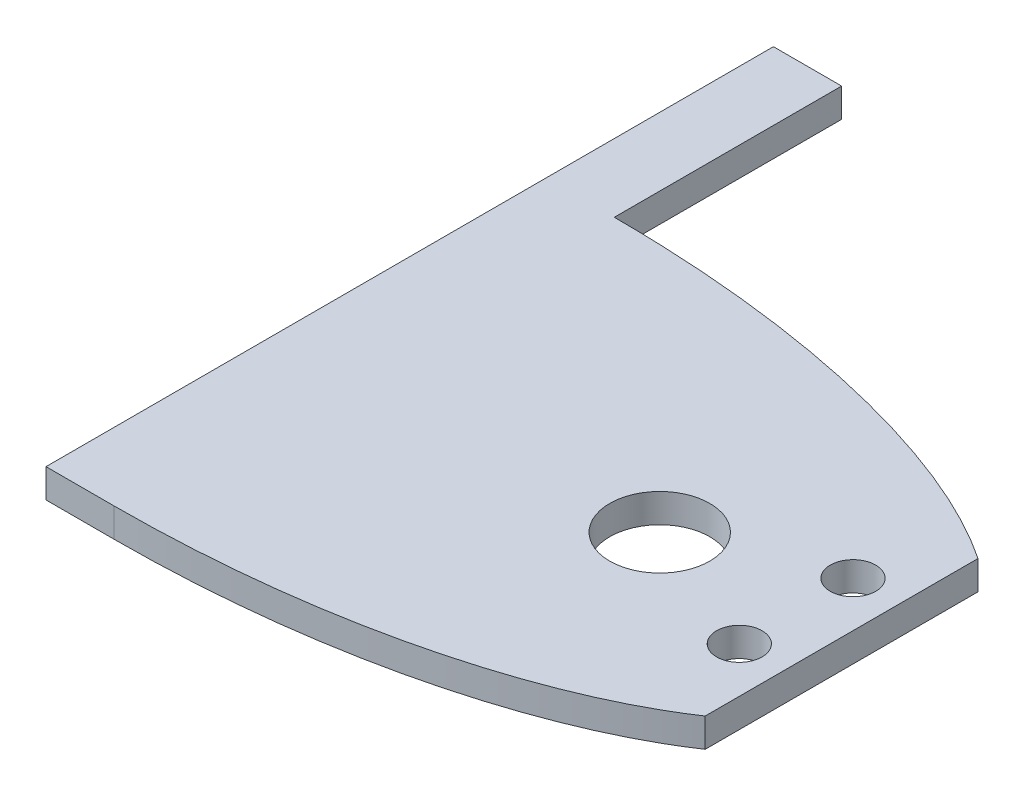
from build123d import *

# Parameters (mm, degrees)
BOSS_EXTRUDE1_DEPTH = 6.35
SKETCH2_R           = 5
CUT_EXTRUDE1_DEPTH  = 6.35
SKETCH3_R           = 11
CUT_EXTRUDE2_DEPTH  = 7.3500001
SKETCH4_W           = 15
SKETCH4_H           = 110
BOSS_EXTRUDE3_DEPTH = 6.35
SKETCH5_W           = 15
SKETCH5_H           = 50
BOSS_EXTRUDE4_DEPTH = 6.35


with BuildPart() as part:
    # Sketch1 → Boss-Extrude1 (new body)
    with BuildSketch(Plane(origin=(0, 0, 0), x_dir=(1, 0, 0), z_dir=(0, 1, 0))):
        with BuildLine():
            Line((0, 110), (0, 0))
            add(Edge.make_bspline(
                [(0, 0), (67.941176471, 0), (105, 25)],
                knots=[1.570796327, 1.570796327, 1.570796327, 2.564661308, 2.564661308, 2.564661308], degree=2, weights=[1, 0.879049073, 1]))
            Line((105, 25), (105, 85))
            add(Edge.make_bspline(
                [(105, 85), (67.941176471, 110), (0, 110)],
                knots=[3.718523999, 3.718523999, 3.718523999, 4.71238898, 4.71238898, 4.71238898], degree=2, weights=[1, 0.879049073, 1]))
        make_face()
    extrude(amount=BOSS_EXTRUDE1_DEPTH)

    # Sketch2 → Cut-Extrude1 (cut)
    with BuildSketch(Plane(origin=(0, 0, 0), x_dir=(1, 0, 0), z_dir=(0, 1, 0))):
        with Locations((95, 67.5)):
            Circle(SKETCH2_R)
        with Locations((95, 42.5)):
            Circle(SKETCH2_R)
    extrude(amount=CUT_EXTRUDE1_DEPTH, mode=Mode.SUBTRACT)

    # Sketch3 → Cut-Extrude2 (cut, through all)
    with BuildSketch(Plane(origin=(0, 0, 0), x_dir=(1, 0, 0), z_dir=(0, 1, 0))):
        with Locations((65, 55)):
            Circle(SKETCH3_R)
    extrude(amount=CUT_EXTRUDE2_DEPTH, mode=Mode.SUBTRACT)

    # Sketch4 → Boss-Extrude3 (add)
    with BuildSketch(Plane(origin=(0, 0, 0), x_dir=(1, 0, 0), z_dir=(0, 1, 0))):
        with Locations((-7.5, 55)):
            Rectangle(SKETCH4_W, SKETCH4_H)
    extrude(amount=BOSS_EXTRUDE3_DEPTH)

    # Sketch5 → Boss-Extrude4 (add)
    with BuildSketch(Plane(origin=(0, 0, 0), x_dir=(1, 0, 0), z_dir=(0, 1, 0))):
        with Locations((-7.5, 135)):
            Rectangle(SKETCH5_W, SKETCH5_H)
    extrude(amount=BOSS_EXTRUDE4_DEPTH)


solid = part.part
